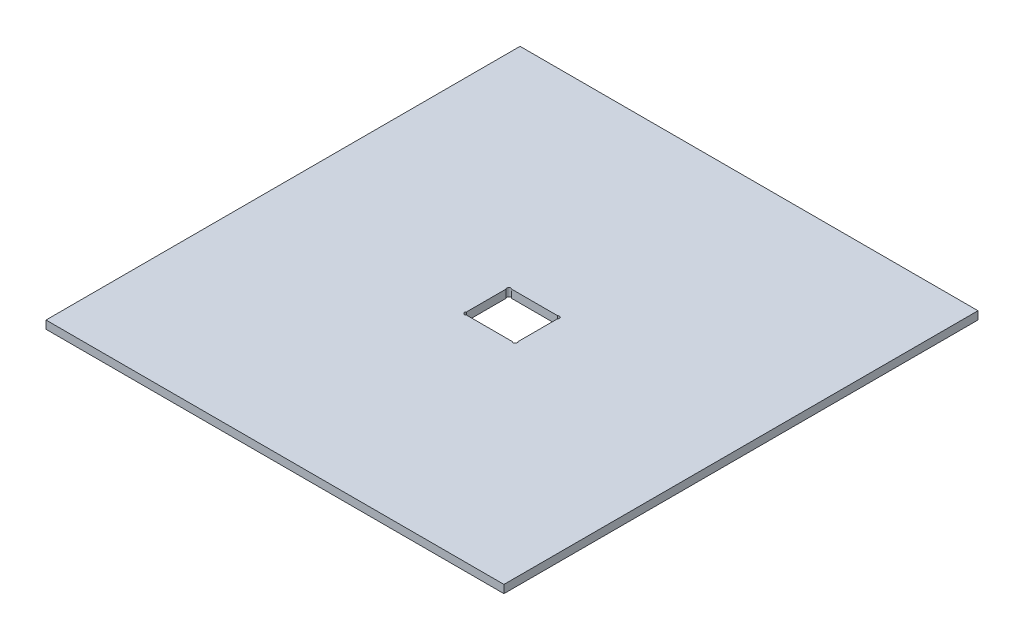
from build123d import *

# Parameters (mm, degrees)
SKETCH1_W           = 180.975
SKETCH1_H           = 187.325
BOSS_EXTRUDE1_DEPTH = 3.175
SKETCH2_W           = 20.32
SKETCH2_H           = 17.78
CUT_EXTRUDE1_DEPTH  = 4.175
SKETCH3_R           = 0.79375
CUT_EXTRUDE2_DEPTH  = 3.175
SKETCH4_W           = 180.975
SKETCH4_H           = 187.325
SKETCH4_W_2         = 180.7718
SKETCH4_H_2         = 187.1218
CUT_EXTRUDE3_DEPTH  = 3.175


with BuildPart() as part:
    # Sketch1 → Boss-Extrude1 (new body)
    with BuildSketch(Plane(origin=(0, 0, 0), x_dir=(1, 0, 0), z_dir=(0, 1, 0))):
        with Locations((90.4875, 93.6625)):
            Rectangle(SKETCH1_W, SKETCH1_H)
    extrude(amount=BOSS_EXTRUDE1_DEPTH)

    # Sketch2 → Cut-Extrude1 (cut, through all)
    with BuildSketch(Plane(origin=(0, 3.175, 0), x_dir=(1, 0, 0), z_dir=(0, 1, 0))):
        with Locations((90.4875, 93.6625)):
            Rectangle(SKETCH2_W, SKETCH2_H)
    extrude(amount=-CUT_EXTRUDE1_DEPTH, mode=Mode.SUBTRACT)

    # Sketch3 → Cut-Extrude2 (cut)
    with BuildSketch(Plane(origin=(0, 3.175, 0), x_dir=(1, 0, 0), z_dir=(0, 1, 0))):
        with Locations((80.888766008, 101.991233992)):
            Circle(SKETCH3_R)
        with Locations((100.086233992, 101.991233992)):
            Circle(SKETCH3_R)
        with Locations((80.888766008, 85.333766008)):
            Circle(SKETCH3_R)
        with Locations((100.086233992, 85.333766008)):
            Circle(SKETCH3_R)
    extrude(amount=-CUT_EXTRUDE2_DEPTH, mode=Mode.SUBTRACT)

    # Sketch4 → Cut-Extrude3 (cut)
    with BuildSketch(Plane(origin=(0, 3.175, 0), x_dir=(1, 0, 0), z_dir=(0, 1, 0))):
        with Locations((90.4875, 93.6625)):
            Rectangle(SKETCH4_W, SKETCH4_H)
        with Locations((90.4875, 93.6625)):
            Rectangle(SKETCH4_W_2, SKETCH4_H_2, mode=Mode.SUBTRACT)
    extrude(amount=-CUT_EXTRUDE3_DEPTH, mode=Mode.SUBTRACT)


solid = part.part
